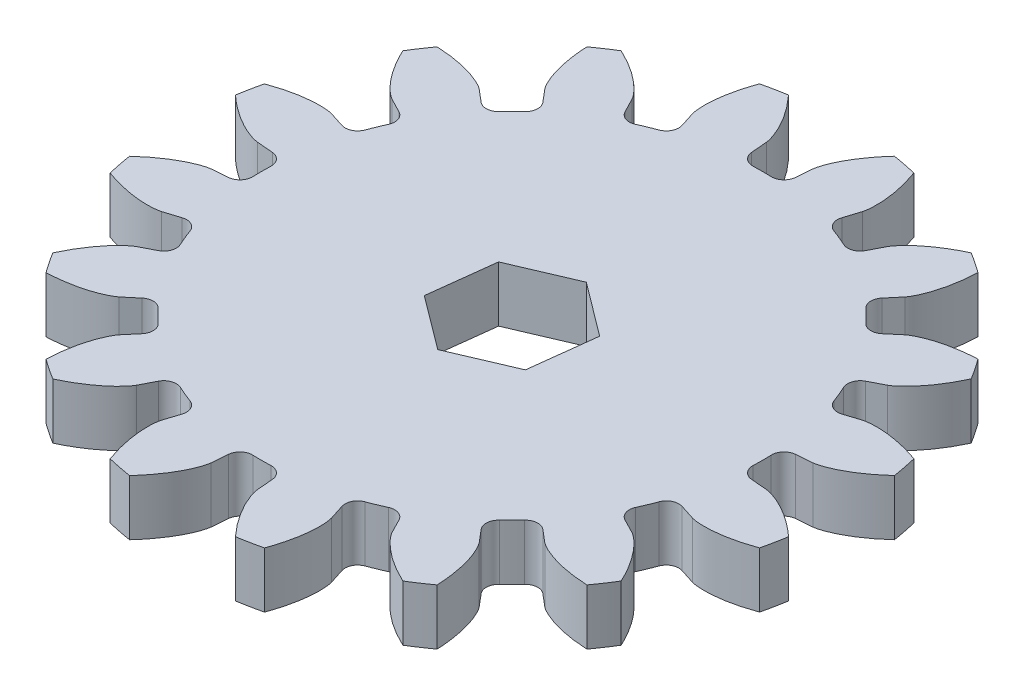
from build123d import *

# Parameters (mm, degrees)
SKETCH1_R                = 38.1
BOSS_EXTRUDE1_DEPTH      = 6.35
CUT_EXTRUDE1_DEPTH       = 6.35
FILLET1_R                = 1.420304652
CIRPATTERN2_COUNT        = 16
FILLET1_OF_CIRPATTERN2_R = 1.420304652
CUT_EXTRUDE2_REACH       = 8.35


with BuildPart() as part:
    # Sketch1 → Boss-Extrude1 (new body)
    with BuildSketch(Plane(origin=(0, 0, 0), x_dir=(1, 0, 0), z_dir=(0, 1, 0))):
        Circle(SKETCH1_R)
    extrude(amount=BOSS_EXTRUDE1_DEPTH)

    # Sketch2 → Cut-Extrude1 (cut)
    with BuildSketch(Plane(origin=(0, 6.35, 0), x_dir=(1, 0, 0), z_dir=(0, 1, 0))):
        with BuildLine():
            Line((31.713986478, 2.646956705), (28.475988317, 2.376702413))
            ThreePointArc((28.475988317, 2.376702413), (28.575, 0), (28.475988317, -2.376702413))
            Line((28.475988317, -2.376702413), (31.713986478, -2.646956705))
            add(Edge.make_bspline(
                [(31.713986478, -2.646956705), (31.724133648, -2.647946086), (31.752551021, -2.651158667), (31.806097095, -2.658959489), (31.893163303, -2.674135444), (32.003605461, -2.69706228), (32.145706951, -2.730805573), (32.312197751, -2.775826939), (32.494121083, -2.830806936), (32.690819084, -2.896537344), (32.885892647, -2.967324079), (33.079335515, -3.042766875), (33.270948771, -3.122263069), (33.501693412, -3.223665483), (33.776437636, -3.352341887), (34.094542984, -3.512992553), (34.451594897, -3.707234071), (34.811231652, -3.917951636), (35.161523578, -4.135740962), (35.511057469, -4.367663437), (35.84612123, -4.600468908), (36.189343497, -4.854277638), (36.503731598, -5.094672864), (36.850353933, -5.37710528), (37.128467991, -5.608873065), (37.410896397, -5.859092987), (37.547629703, -5.982464574), (37.617199362, -6.046181621)],
                knots=[0, 0, 0, 0, 0, 0.005376749, 0.015083688, 0.02853182, 0.04661014, 0.064854849, 0.092110526, 0.119476176, 0.146842496, 0.174208854, 0.201574956, 0.228941013, 0.256307345, 0.307035032, 0.361767352, 0.416499661, 0.471231937, 0.525964282, 0.580696616, 0.635428982, 0.690161387, 0.744893688, 0.799626082, 0.854358408, 0.909090915, 0.909090915, 0.909090915, 0.909090915, 0.909090915], degree=4))
            ThreePointArc((37.617199362, -6.046181621), (38.1, 0), (37.617199362, 6.046181621))
            add(Edge.make_bspline(
                [(31.713986478, 2.646956705), (31.724133648, 2.647946086), (31.752551021, 2.651158667), (31.806097095, 2.658959489), (31.893163303, 2.674135444), (32.003605461, 2.69706228), (32.145706951, 2.730805573), (32.312197751, 2.775826939), (32.494121083, 2.830806936), (32.690819084, 2.896537344), (32.885892647, 2.967324079), (33.079335515, 3.042766875), (33.270948771, 3.122263069), (33.501693412, 3.223665483), (33.776437636, 3.352341887), (34.094542984, 3.512992553), (34.451594897, 3.707234071), (34.811231652, 3.917951636), (35.161523578, 4.135740962), (35.511057469, 4.367663437), (35.84612123, 4.600468908), (36.189343497, 4.854277638), (36.503731598, 5.094672864), (36.850353933, 5.37710528), (37.128467991, 5.608873065), (37.410896397, 5.859092987), (37.547629703, 5.982464574), (37.617199362, 6.046181621)],
                knots=[0, 0, 0, 0, 0, 0.005376749, 0.015083688, 0.02853182, 0.04661014, 0.064854849, 0.092110526, 0.119476176, 0.146842496, 0.174208854, 0.201574956, 0.228941013, 0.256307345, 0.307035032, 0.361767352, 0.416499661, 0.471231937, 0.525964282, 0.580696616, 0.635428982, 0.690161387, 0.744893688, 0.799626082, 0.854358408, 0.909090915, 0.909090915, 0.909090915, 0.909090915, 0.909090915], degree=4))
        make_face()
    cut_extrude1 = extrude(amount=-CUT_EXTRUDE1_DEPTH, mode=Mode.SUBTRACT)

    # Fillet1
    fillet1_edges = [part.edges().sort_by_distance(p)[0] for p in [
        (28.475988317, 3.175, 2.376702413),
        (28.475988317, 3.175, -2.376702413),
    ]]
    fillet(fillet1_edges, radius=FILLET1_R)

    # CirPattern2: Cut-Extrude1 ×16 about axis
    cirpattern2_axis = Axis((0, 6.35, 0), (0, -1, 0))
    for i in range(1, CIRPATTERN2_COUNT):
        add(cut_extrude1.rotate(cirpattern2_axis, i * 360 / CIRPATTERN2_COUNT), mode=Mode.SUBTRACT)

    # Fillet1 of CirPattern2
    fillet1_of_cirpattern2_edges = [part.edges().sort_by_distance(p)[0] for p in [
        (25.398858137, 3.175, 13.093075664),
        (27.217907412, 3.175, 8.701502235),
        (18.454982047, 3.175, 21.816146833),
        (21.816146833, 3.175, 18.454982047),
        (8.701502235, 3.175, 27.217907412),
        (13.093075664, 3.175, 25.398858137),
        (-2.376702413, 3.175, 28.475988317),
        (2.376702413, 3.175, 28.475988317),
        (-13.093075664, 3.175, 25.398858137),
        (-8.701502235, 3.175, 27.217907412),
        (-21.816146833, 3.175, 18.454982047),
        (-18.454982047, 3.175, 21.816146833),
        (-27.217907412, 3.175, 8.701502235),
        (-25.398858137, 3.175, 13.093075664),
        (-28.475988317, 3.175, -2.376702413),
        (-28.475988317, 3.175, 2.376702413),
        (-25.398858137, 3.175, -13.093075664),
        (-27.217907412, 3.175, -8.701502235),
        (-18.454982047, 3.175, -21.816146833),
        (-21.816146833, 3.175, -18.454982047),
        (-8.701502235, 3.175, -27.217907412),
        (-13.093075664, 3.175, -25.398858137),
        (2.376702413, 3.175, -28.475988317),
        (-2.376702413, 3.175, -28.475988317),
        (13.093075664, 3.175, -25.398858137),
        (8.701502235, 3.175, -27.217907412),
        (21.816146833, 3.175, -18.454982047),
        (18.454982047, 3.175, -21.816146833),
        (27.217907412, 3.175, -8.701502235),
        (25.398858137, 3.175, -13.093075664),
    ]]
    fillet(fillet1_of_cirpattern2_edges, radius=FILLET1_OF_CIRPATTERN2_R)

    # Sketch3 → Cut-Extrude2 (cut, up to next)
    with BuildSketch(Plane(origin=(0, 6.35, 0), x_dir=(1, 0, 0), z_dir=(0, 1, 0)), mode=Mode.PRIVATE) as cut_extrude2_sk1:
        Polygon((-0.908203885, -7.57136626), (6.10289358, -4.572210766), (7.011097465, 2.999155494), (0.908203885, 7.57136626), (-6.10289358, 4.572210766), (-7.011097465, -2.999155494), align=None)
    cut_extrude2_tool1 = extrude(cut_extrude2_sk1.sketch, amount=-CUT_EXTRUDE2_REACH, mode=Mode.PRIVATE) & part.part
    add(cut_extrude2_tool1.solids().sort_by_distance((0, 6.35, 0))[0], mode=Mode.SUBTRACT)


solid = part.part
